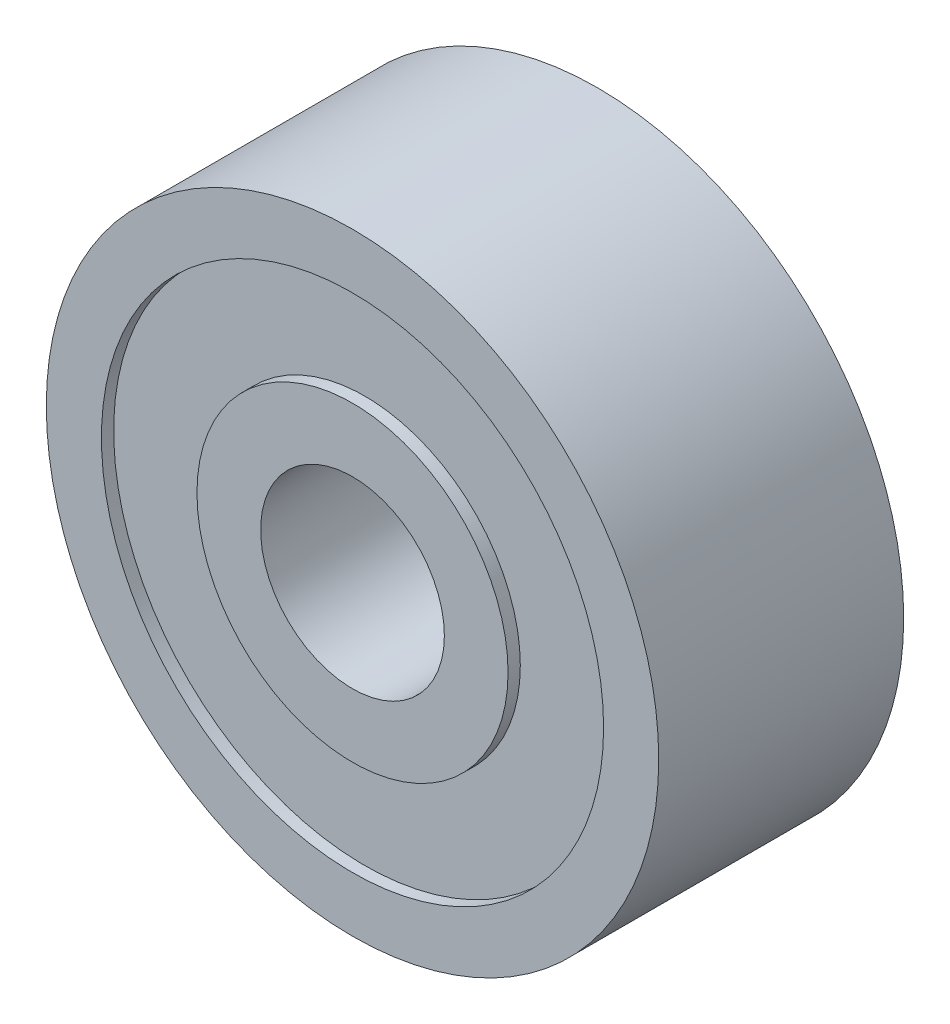
from build123d import *

# Parameters (mm, degrees)
SKETCH_1_R          = 5
EXTRUDE_1_DEPTH     = 2
SKETCH_2_R          = 1.5
CUT_EXTRUDE_1_DEPTH = 5
SKETCH_3_R          = 4.1
SKETCH_3_R_2        = 2.54
CUT_EXTRUDE_2_DEPTH = 0.2


with BuildPart() as part:
    # 草圖1 → 填料-伸長1 (new body, symmetric)
    with BuildSketch(Plane.XY):
        Circle(SKETCH_1_R)
    extrude(amount=EXTRUDE_1_DEPTH, both=True)

    # 草圖2 → 除料-伸長1 (cut, through all)
    with BuildSketch(Plane.XY.offset(2)):
        Circle(SKETCH_2_R)
    extrude(amount=-CUT_EXTRUDE_1_DEPTH, mode=Mode.SUBTRACT)

    # 草圖3 → 除料-伸長2 (cut)
    with BuildSketch(Plane.XY.offset(2)):
        Circle(SKETCH_3_R)
        Circle(SKETCH_3_R_2, mode=Mode.SUBTRACT)
    cut_extrude_2 = extrude(amount=-CUT_EXTRUDE_2_DEPTH, mode=Mode.SUBTRACT)

    # 鏡射1: 除料-伸長2 across plane
    add(cut_extrude_2.mirror(Plane.XY), mode=Mode.SUBTRACT)


solid = part.part
